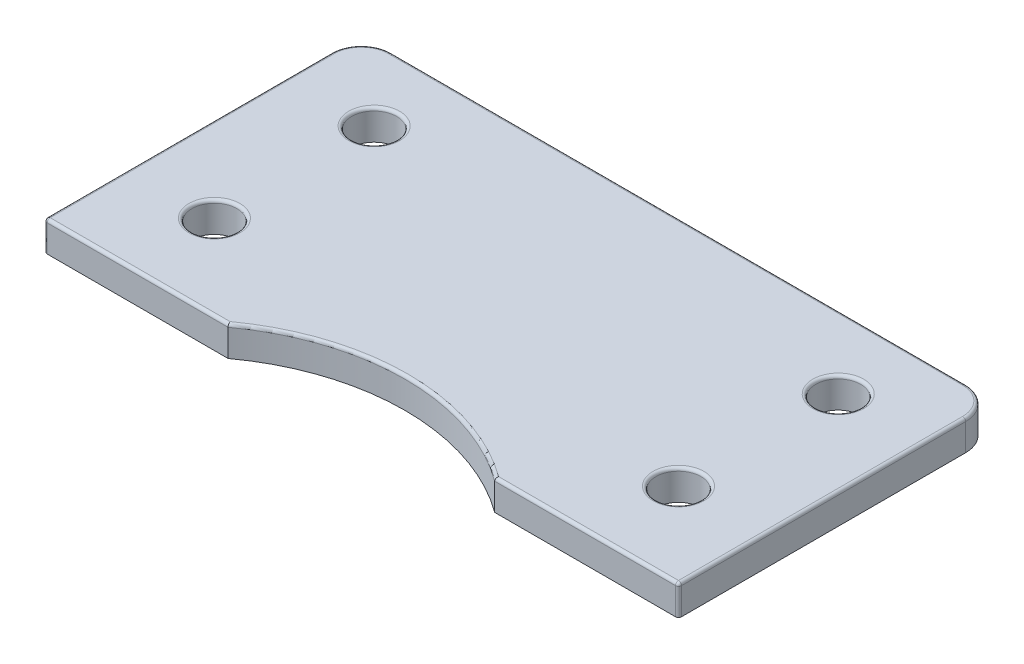
from build123d import *

# Parameters (mm, degrees)
SKETCH1_R           = 1.5
BOSS_EXTRUDE1_DEPTH = 2
FILLET1_R           = 2
FILLET2_R           = 0.2


with BuildPart() as part:
    # Sketch1 → Boss-Extrude1 (new body)
    with BuildSketch(Plane(origin=(0, 0, 0), x_dir=(1, 0, 0), z_dir=(0, 1, 0))):
        with BuildLine():
            Line((-21.15, -21.15), (-8.891728161, -21.15))
            ThreePointArc((-8.891728161, -21.15), (0, -18.248189838), (8.891728161, -21.15))
            Line((8.891728161, -21.15), (21.15, -21.15))
            Line((21.15, -21.15), (21.15, 0))
            Line((21.15, 0), (-21.15, 0))
            Line((-21.15, 0), (-21.15, -21.15))
        make_face()
        with Locations((15.5, -4.847889014)):
            Circle(SKETCH1_R, mode=Mode.SUBTRACT)
        with Locations((-15.449717978, -15.5)):
            Circle(SKETCH1_R, mode=Mode.SUBTRACT)
        with Locations((15.5, -15.5)):
            Circle(SKETCH1_R, mode=Mode.SUBTRACT)
        with Locations((-15.449717978, -4.847889014)):
            Circle(SKETCH1_R, mode=Mode.SUBTRACT)
    extrude(amount=BOSS_EXTRUDE1_DEPTH)

    # Fillet1
    fillet1_edges = [part.edges().sort_by_distance(p)[0] for p in [
        (-21.15, 1, 0),
        (21.15, 1, 0),
    ]]
    fillet(fillet1_edges, radius=FILLET1_R)

    # Fillet2
    fillet2_edges = [part.edges().sort_by_distance(p)[0] for p in [
        (0, 2, 18.248189838),
        (21.15, 1, 21.15),
        (-21.15, 1, 21.15),
        (15.02086408, 2, 21.15),
        (21.15, 2, 11.575),
        (-16.949717978, 2, 15.5),
        (14, 2, 15.5),
        (14, 2, 4.847889014),
        (-16.949717978, 2, 4.847889014),
        (-21.15, 2, 11.575),
        (0, 2, 0),
        (20.564213562, 2, 0.585786438),
        (-20.564213562, 2, 0.585786438),
        (-15.02086408, 2, 21.15),
    ]]
    fillet(fillet2_edges, radius=FILLET2_R)


solid = part.part
